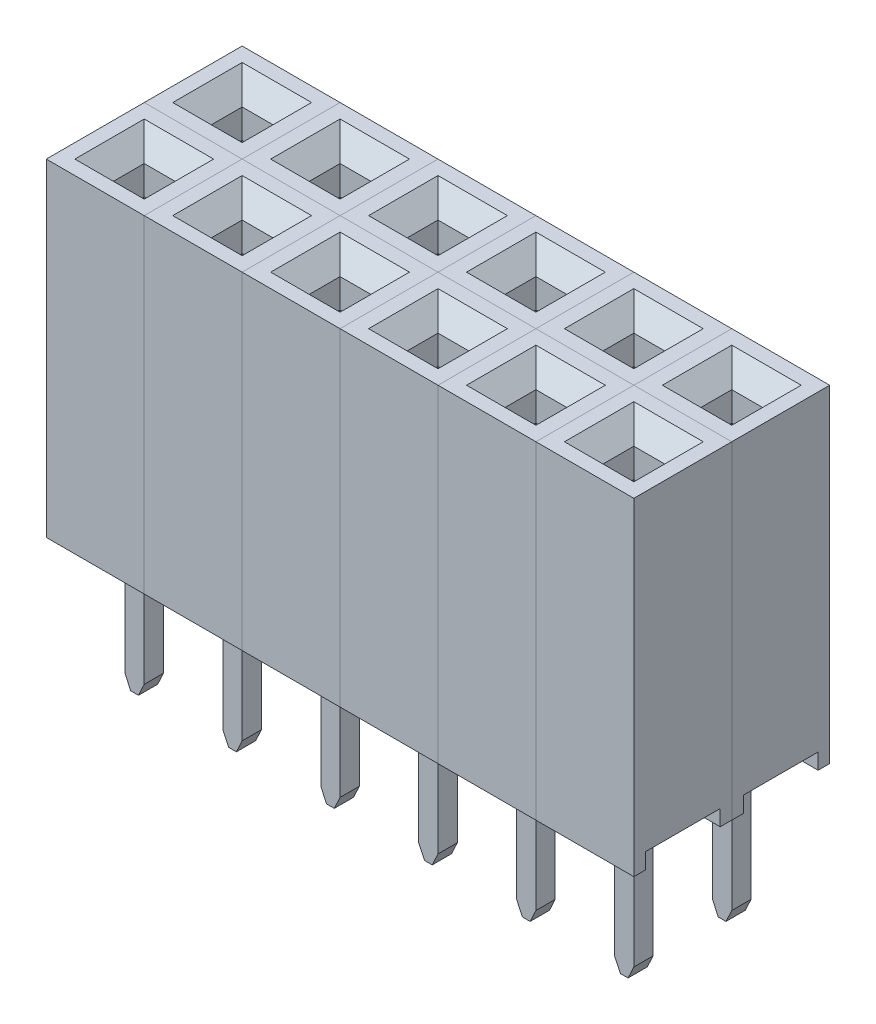
from build123d import *

# Parameters (mm, degrees)
SKETCH1_W               = 2.54
SKETCH1_H               = 8.5
BOSS_EXTRUDE1_DEPTH     = 1.27
SKETCH2_W               = 1.94
SKETCH2_H               = 0.410374384
CUT_EXTRUDE1_DEPTH      = 50
SKETCH4_W               = 0.8
SKETCH4_H               = 0.8
CUT_EXTRUDE2_DEPTH      = 1.5
CHAMFER1_SIZE           = 0.5
SKETCH5_W               = 1.8
SKETCH5_H               = 1.8
CUT_EXTRUDE3_DEPTH      = 3
CUT_EXTRUDE3_DEPTH_BACK = 3
BOSS_EXTRUDE4_DEPTH     = 0.85
BOSS_EXTRUDE5_DEPTH     = 0.25
LPATTERN1_COUNT         = 6
LPATTERN1_PITCH         = 2.54
LPATTERN1_2_COUNT       = 2
LPATTERN1_2_PITCH       = 2.54


with BuildPart() as part:
    # Sketch1 → Boss-Extrude1 (new body, symmetric)
    with BuildSketch(Plane.XY):
        Rectangle(SKETCH1_W, SKETCH1_H)
    extrude(amount=BOSS_EXTRUDE1_DEPTH, both=True)

    # Sketch2 → Cut-Extrude1 (cut, symmetric)
    with BuildSketch(Plane(origin=(0, 0, 0), x_dir=(0, 0, -1), z_dir=(1, 0, 0))):
        with Locations((0, -4.044812808)):
            Rectangle(SKETCH2_W, SKETCH2_H)
    extrude(amount=CUT_EXTRUDE1_DEPTH, both=True, mode=Mode.SUBTRACT)

    # Sketch4 → Cut-Extrude2 (cut)
    with BuildSketch(Plane(origin=(0, 4.25, 0), x_dir=(1, 0, 0), z_dir=(0, 1, 0))):
        Rectangle(SKETCH4_W, SKETCH4_H)
    extrude(amount=-CUT_EXTRUDE2_DEPTH, mode=Mode.SUBTRACT)

    # Chamfer1
    chamfer1_edges = [part.edges().sort_by_distance(p)[0] for p in [
        (0.4, 4.25, 0),
        (0, 4.25, -0.4),
        (-0.4, 4.25, 0),
        (0, 4.25, 0.4),
    ]]
    chamfer(chamfer1_edges, length=CHAMFER1_SIZE)

    # Sketch5 → Cut-Extrude3 (cut, two sides)
    with BuildSketch(Plane(origin=(0, 0, 0), x_dir=(1, 0, 0), z_dir=(0, 1, 0))) as cut_extrude3_sk:
        Rectangle(SKETCH5_W, SKETCH5_H)
    extrude(amount=CUT_EXTRUDE3_DEPTH, mode=Mode.SUBTRACT)
    extrude(cut_extrude3_sk.sketch, amount=-CUT_EXTRUDE3_DEPTH_BACK, mode=Mode.SUBTRACT)

    # Sketch9 → Boss-Extrude4 (add, symmetric)
    with BuildSketch(Plane.XY):
        with BuildLine():
            Line((0.852765845, -1.341648528), (0.602186386, -1.260876719))
            Line((0.602186386, -1.260876719), (0.413271806, 1.491878581))
            ThreePointArc((0.413271806, 1.491878581), (0.162585139, 1.576117793), (0.280281264, 1.339289432))
            Line((0.280281264, 1.339289432), (0.507505583, -1.97169351))
            ThreePointArc((0.507505583, -1.97169351), (0.361743925, -2.312679398), (0, -2.394283131))
            ThreePointArc((0, -2.394283131), (-0.361743925, -2.312679398), (-0.507505583, -1.97169351))
            Line((-0.507505583, -1.97169351), (-0.280281264, 1.339289432))
            ThreePointArc((-0.280281264, 1.339289432), (-0.162585139, 1.576117793), (-0.413271806, 1.491878581))
            Line((-0.413271806, 1.491878581), (-0.602186386, -1.260876719))
            Line((-0.602186386, -1.260876719), (-0.852765845, -1.341648528))
            Line((-0.852765845, -1.341648528), (-0.852765845, -2.693306042))
            Line((-0.852765845, -2.693306042), (-0.280728289, -3.053320584))
            Line((-0.280728289, -3.053320584), (0.280728289, -3.053320584))
            Line((0.280728289, -3.053320584), (0.852765845, -2.693306042))
            Line((0.852765845, -2.693306042), (0.852765845, -1.341648528))
        make_face()
    extrude(amount=BOSS_EXTRUDE4_DEPTH, both=True)

    # Sketch9_3 → Boss-Extrude5 (add, symmetric)
    with BuildSketch(Plane.XY):
        Polygon((0.25, -7.299491593), (0.25, -3.053320584), (-0.25, -3.053320584), (-0.25, -7.299491593), (-0.1, -7.621167632), (0.1, -7.621167632), align=None)
    extrude(amount=BOSS_EXTRUDE5_DEPTH, both=True)


with BuildPart() as lpattern1_1:
    # LPattern1: pattern copy
    add(part.part.moved(Location(Vector(-1, 0, 0) * (1 * LPATTERN1_PITCH))))


with BuildPart() as lpattern1_2:
    # LPattern1: pattern copy
    add(part.part.moved(Location(Vector(-1, 0, 0) * (2 * LPATTERN1_PITCH))))


with BuildPart() as lpattern1_3:
    # LPattern1: pattern copy
    add(part.part.moved(Location(Vector(-1, 0, 0) * (3 * LPATTERN1_PITCH))))


with BuildPart() as lpattern1_4:
    # LPattern1: pattern copy
    add(part.part.moved(Location(Vector(-1, 0, 0) * (4 * LPATTERN1_PITCH))))


with BuildPart() as lpattern1_5:
    # LPattern1: pattern copy
    add(part.part.moved(Location(Vector(-1, 0, 0) * (5 * LPATTERN1_PITCH))))


with BuildPart() as lpattern1_2_1:
    # LPattern1 2: pattern copy
    add(part.part.moved(Location(Vector(0, 0, -1) * (1 * LPATTERN1_2_PITCH))))


with BuildPart() as lpattern1_2_2:
    # LPattern1 2: pattern copy
    add(lpattern1_1.part.moved(Location(Vector(0, 0, -1) * (1 * LPATTERN1_2_PITCH))))


with BuildPart() as lpattern1_2_3:
    # LPattern1 2: pattern copy
    add(lpattern1_2.part.moved(Location(Vector(0, 0, -1) * (1 * LPATTERN1_2_PITCH))))


with BuildPart() as lpattern1_2_4:
    # LPattern1 2: pattern copy
    add(lpattern1_3.part.moved(Location(Vector(0, 0, -1) * (1 * LPATTERN1_2_PITCH))))


with BuildPart() as lpattern1_2_5:
    # LPattern1 2: pattern copy
    add(lpattern1_4.part.moved(Location(Vector(0, 0, -1) * (1 * LPATTERN1_2_PITCH))))


with BuildPart() as lpattern1_2_6:
    # LPattern1 2: pattern copy
    add(lpattern1_5.part.moved(Location(Vector(0, 0, -1) * (1 * LPATTERN1_2_PITCH))))


solid = Compound([part.part, lpattern1_1.part, lpattern1_2.part, lpattern1_3.part, lpattern1_4.part, lpattern1_5.part, lpattern1_2_1.part, lpattern1_2_2.part, lpattern1_2_3.part, lpattern1_2_4.part, lpattern1_2_5.part, lpattern1_2_6.part])
